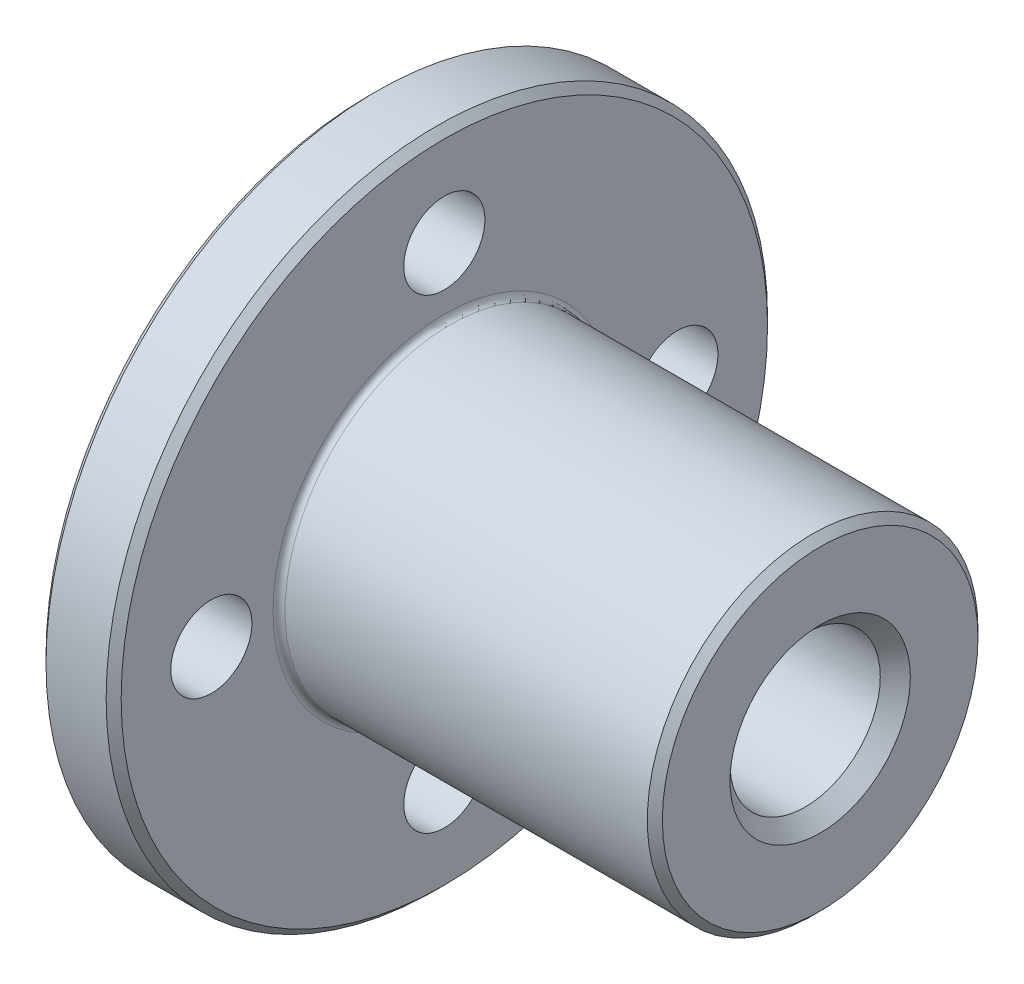
from build123d import *

# Parameters (mm, degrees)
SKETCH1_W      = 5
SKETCH1_H      = 22
SKETCH2_R      = 11
EXTRUDE1_DEPTH = 25
HOLEWZD1_D     = 5.4
HOLEWZD2_D     = 10
HOLEWZD2_DEPTH = 30
CHAMFER1_SIZE  = 0.5
CHAMFER2_SIZE  = 1
FILLET1_R      = 0.4


with BuildPart() as part:
    # Sketch1 → Revolve1 (revolve)
    with BuildSketch(Plane(origin=(0, 0, 0), x_dir=(-1, 0, 0), z_dir=(0, 0, -1))):
        with Locations((-2.5, 11)):
            Rectangle(SKETCH1_W, SKETCH1_H)
    revolve(axis=Axis((5, 0, 0), (-1, 0, 0)))

    # Sketch2 → Extrude1 (add)
    with BuildSketch(Plane(origin=(5, 0, 0), x_dir=(0, 0, -1), z_dir=(1, 0, 0))):
        Circle(SKETCH2_R)
    extrude(amount=EXTRUDE1_DEPTH)

    # HoleWzd1 (through all)
    with Locations(Plane(origin=(5, 0, 0), x_dir=(0, 0, -1), z_dir=(1, 0, 0))):
        with Locations((0, -15.5), (15.5, 0), (-15.5, 0), (0, 15.5)):
            Hole(HOLEWZD1_D / 2)

    # HoleWzd2
    with Locations(Plane(origin=(30, 0, 0), x_dir=(0, 0, -1), z_dir=(1, 0, 0))):
        with Locations((0, 0)):
            Hole(HOLEWZD2_D / 2, depth=HOLEWZD2_DEPTH)

    # Chamfer1
    chamfer1_edges = [part.edges().sort_by_distance(p)[0] for p in [
        (0, -22, 0),
        (5, -22, 0),
        (30, 0, 11),
    ]]
    chamfer(chamfer1_edges, length=CHAMFER1_SIZE)

    # Chamfer2
    chamfer2_edges = [part.edges().sort_by_distance(p)[0] for p in [
        (30, 0, -5),
        (0, 0, -5),
    ]]
    chamfer(chamfer2_edges, length=CHAMFER2_SIZE)

    # Fillet1
    fillet1_edges = [part.edges().sort_by_distance(p)[0] for p in [
        (5, 0, 11),
    ]]
    fillet(fillet1_edges, radius=FILLET1_R)


solid = part.part
